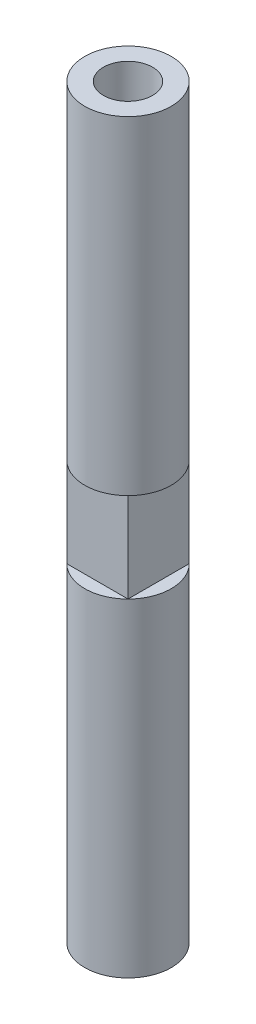
from build123d import *

# Parameters (mm, degrees)
SKETCH1_R           = 3.683
BOSS_EXTRUDE1_DEPTH = 63.5
SKETCH7_R           = 2.09
CUT_EXTRUDE1_DEPTH  = 20.32
SKETCH8_OUTSIDE_W   = 22.236
SKETCH8_OUTSIDE_H   = 22.236
SKETCH8_OUTSIDE_W_2 = 5.20854855
SKETCH8_OUTSIDE_H_2 = 5.20854855
CUT_EXTRUDE3_DEPTH  = 3.81


with BuildPart() as part:
    # Sketch1 → Boss-Extrude1 (new body)
    with BuildSketch(Plane(origin=(0, 0, 0), x_dir=(1, 0, 0), z_dir=(0, 1, 0))):
        Circle(SKETCH1_R)
    extrude(amount=BOSS_EXTRUDE1_DEPTH)

    # Sketch7 → Cut-Extrude1 (cut)
    with BuildSketch(Plane.XZ):
        Circle(SKETCH7_R)
    cut_extrude1 = extrude(amount=-CUT_EXTRUDE1_DEPTH, mode=Mode.SUBTRACT)

    # Mirror1: Cut-Extrude1 across plane
    add(cut_extrude1.mirror(Plane(origin=(0, 31.75, 0), x_dir=(0, 0, 1), z_dir=(0, -1, 0))), mode=Mode.SUBTRACT)

    # Sketch8 outside → Cut-Extrude3 (cut, symmetric)
    with BuildSketch(Plane(origin=(0, 31.75, 0), x_dir=(-1, 0, 0), z_dir=(0, -1, 0))):
        Rectangle(SKETCH8_OUTSIDE_W, SKETCH8_OUTSIDE_H)
        Rectangle(SKETCH8_OUTSIDE_W_2, SKETCH8_OUTSIDE_H_2, mode=Mode.SUBTRACT)
    extrude(amount=CUT_EXTRUDE3_DEPTH, both=True, mode=Mode.SUBTRACT)


solid = part.part
